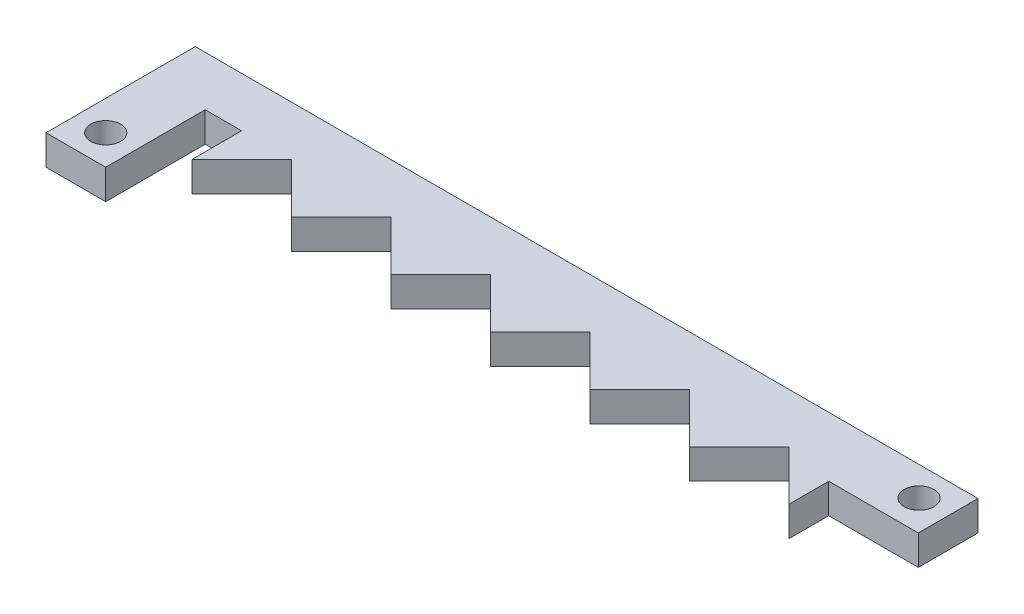
from build123d import *

# Parameters (mm, degrees)
SKETCH1_R           = 1.5
BOSS_EXTRUDE1_DEPTH = 3


with BuildPart() as part:
    # Sketch1 → Boss-Extrude1 (new body)
    with BuildSketch(Plane(origin=(0, 0, 0), x_dir=(1, 0, 0), z_dir=(0, 1, 0))):
        Polygon((1.765756862, 34.483992996), (6.765756862, 39.483992996), (11.765756862, 34.483992996), (16.765756862, 39.483992996), (21.765756862, 34.483992996), (26.765756862, 39.483992996), (31.765756862, 34.483992996), (36.765756862, 39.483992996), (41.765756862, 34.483992996), (46.765756862, 39.483992996), (51.765756862, 34.483992996), (56.765756862, 39.483992996), (61.765756862, 34.483992996), (61.765756862, 38.483992996), (70.765756862, 38.483992996), (70.765756862, 44.483992996), (1, 44.483992996), (-5.848815236, 44.483992996), (-7.891171506, 44.483992996), (-7.891171506, 29.483992996), (-1.891171506, 29.483992996), (-1.891171506, 39.483992996), (1.765756862, 39.483992996), align=None)
        with Locations((-4.891171506, 32.483992996)):
            Circle(SKETCH1_R, mode=Mode.SUBTRACT)
        with Locations((67.765756862, 41.557757711)):
            Circle(SKETCH1_R, mode=Mode.SUBTRACT)
    extrude(amount=BOSS_EXTRUDE1_DEPTH)


solid = part.part
